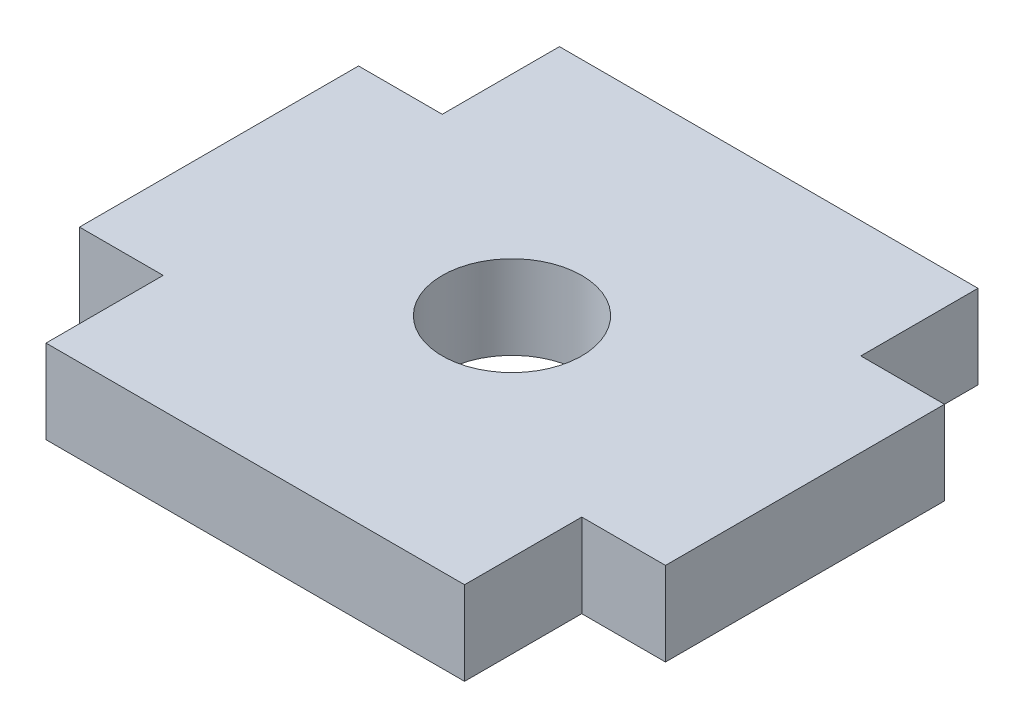
from build123d import *

# Parameters (mm, degrees)
ESBO_O1_R                = 2.5
RESSALTO_EXTRUS_O1_DEPTH = 3


with BuildPart() as part:
    # Esboço1 → Ressalto-extrusão1 (new body)
    with BuildSketch(Plane.XZ.offset(-10)):
        Polygon((-61.5, -9.199919627), (-61.5, -5), (-58.5, -5), (-58.5, 5), (-61.5, 5), (-61.5, 9.199919627), (-76.5, 9.199919627), (-76.5, 5), (-79.5, 5), (-79.5, -5), (-76.5, -5), (-76.5, -9.199919627), align=None)
        with Locations((-69, 0)):
            Circle(ESBO_O1_R, mode=Mode.SUBTRACT)
    extrude(amount=-RESSALTO_EXTRUS_O1_DEPTH)


solid = part.part
